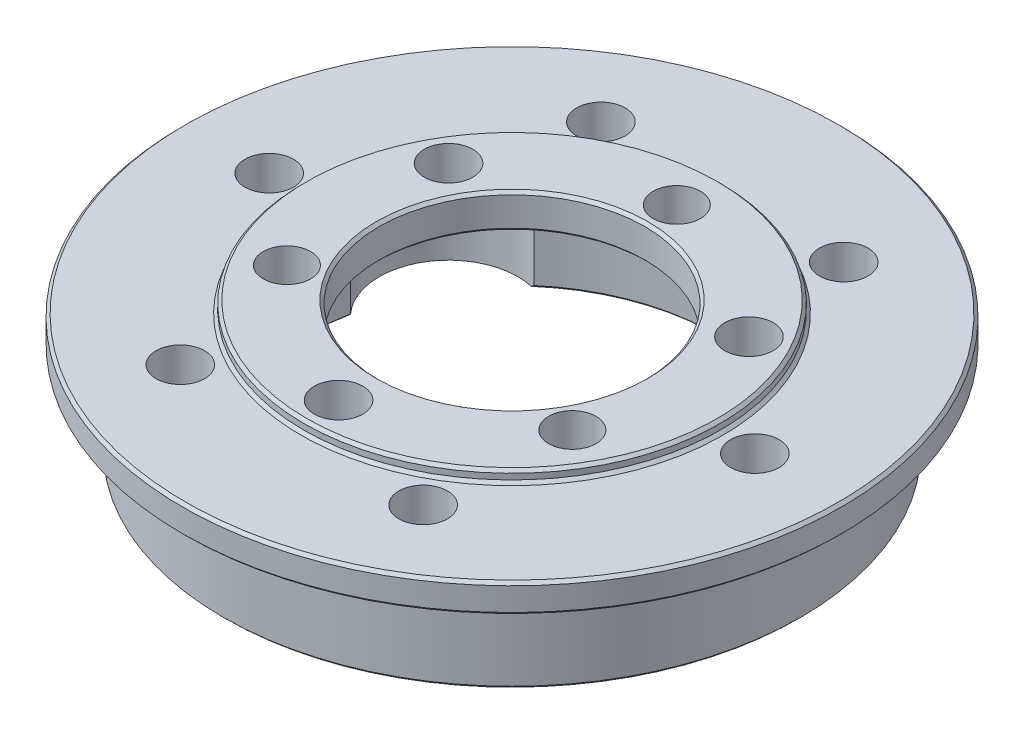
from build123d import *

# Parameters (mm, degrees)
CHAMFER_1_SIZE           = 0.25
SKETCH_2_R               = 2.1
SKETCH_2_R_2             = 2.05
CUT_EXTRUDE_1_DEPTH      = 4
SKETCH_3_R               = 6
CUT_EXTRUDE_2_DEPTH      = 9.5
PATTERN_CIRCULAR_1_COUNT = 3
SKETCH_4_R               = 2.1
CUT_EXTRUDE_3_DEPTH      = 12.5
PATTERN_CIRCULAR_2_COUNT = 6


with BuildPart() as part:
    # 草图1 → 旋转1 (revolve)
    with BuildSketch(Plane.XY):
        Polygon((-25, 0), (-17.5, 0), (-17.5, 8.5), (-11.5, 8.5), (-11.5, 11.5), (-18, 11.5), (-18, 10.5), (-28.5, 10.5), (-28.5, 8), (-25, 8), align=None)
    revolve(axis=Axis((0, 0, 0), (0, 1, 0)))

    # 倒角1
    chamfer_1_edges = [part.edges().sort_by_distance(p)[0] for p in [
        (11.5, 11.5, 0),
        (11.5, 8.5, 0),
        (17.5, 8.5, 0),
        (17.5, 0, 0),
        (25, 0, 0),
        (25, 8, 0),
        (28.5, 8, 0),
        (28.5, 10.5, 0),
        (18, 10.5, 0),
        (18, 11.5, 0),
    ]]
    chamfer(chamfer_1_edges, length=CHAMFER_1_SIZE)

    # 草图2 → 切除-拉伸1 (cut, through all)
    with BuildSketch(Plane.XZ.offset(-8.5)):
        with Locations((0, 15)):
            Circle(SKETCH_2_R)
        with Locations((0, -14.25)):
            Circle(SKETCH_2_R_2)
    cut_extrude_1 = extrude(amount=-CUT_EXTRUDE_1_DEPTH, mode=Mode.SUBTRACT)

    # 草图3 → 切除-拉伸2 (cut, through all)
    with BuildSketch(Plane.XZ.offset(-8.5)):
        with Locations((0, 15)):
            Circle(SKETCH_3_R)
    cut_extrude_2 = extrude(amount=CUT_EXTRUDE_2_DEPTH, mode=Mode.SUBTRACT)

    # 阵列(圆周)1: 切除-拉伸1, 切除-拉伸2 ×3 about axis
    pattern_circular_1_axis = Axis((0, 0, 0), (0, 1, 0))
    for i in range(1, PATTERN_CIRCULAR_1_COUNT):
        add(cut_extrude_1.rotate(pattern_circular_1_axis, i * 360 / PATTERN_CIRCULAR_1_COUNT), mode=Mode.SUBTRACT)
        add(cut_extrude_2.rotate(pattern_circular_1_axis, i * 360 / PATTERN_CIRCULAR_1_COUNT), mode=Mode.SUBTRACT)

    # 草图4 → 切除-拉伸3 (cut, through all)
    with BuildSketch(Plane.XZ):
        with Locations((10.5, 18.186533479)):
            Circle(SKETCH_4_R)
    cut_extrude_3 = extrude(amount=-CUT_EXTRUDE_3_DEPTH, mode=Mode.SUBTRACT)

    # 阵列(圆周)2: 切除-拉伸3 ×6 about axis
    pattern_circular_2_axis = Axis((0, 0, 0), (0, 1, 0))
    for i in range(1, PATTERN_CIRCULAR_2_COUNT):
        add(cut_extrude_3.rotate(pattern_circular_2_axis, i * 360 / PATTERN_CIRCULAR_2_COUNT), mode=Mode.SUBTRACT)


solid = part.part
